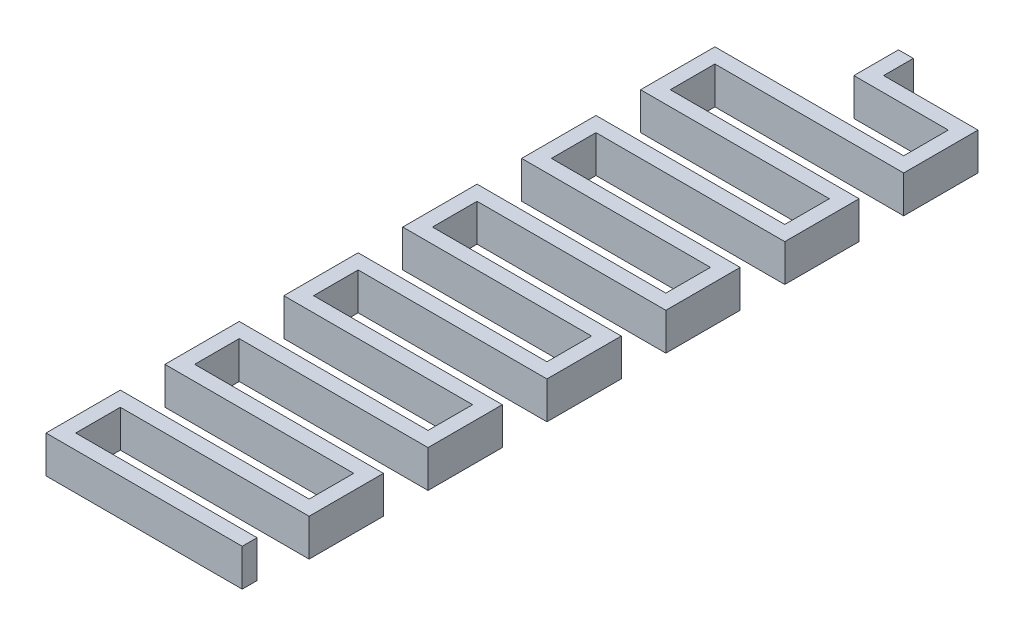
from build123d import *

# Parameters (mm, degrees)
EXTRUDE_THIN1_DEPTH = 5


with BuildPart() as part:
    # Sketch1 → Extrude-Thin1 (new body)
    with BuildSketch(Plane(origin=(0, 0, 0), x_dir=(1, 0, 0), z_dir=(0, 1, 0))):
        Polygon((-1, 0), (-1, -6), (11.7, -6), (11.7, -12), (-13.7, -12), (-13.7, -22), (11.7, -22), (11.7, -28), (-13.7, -28), (-13.7, -38), (11.7, -38), (11.7, -44), (-13.7, -44), (-13.7, -54), (11.7, -54), (11.7, -60), (-13.7, -60), (-13.7, -70), (11.7, -70), (11.7, -76), (-13.7, -76), (-13.7, -86), (11.7, -86), (11.7, -92), (-13.7, -92), (-13.7, -102), (12.7, -102), (12.7, -100), (-11.7, -100), (-11.7, -94), (13.7, -94), (13.7, -84), (-11.7, -84), (-11.7, -78), (13.7, -78), (13.7, -68), (-11.7, -68), (-11.7, -62), (13.7, -62), (13.7, -52), (-11.7, -52), (-11.7, -46), (13.7, -46), (13.7, -36), (-11.7, -36), (-11.7, -30), (13.7, -30), (13.7, -20), (-11.7, -20), (-11.7, -14), (13.7, -14), (13.7, -4), (1, -4), (1, 0), align=None)
    extrude(amount=EXTRUDE_THIN1_DEPTH)


solid = part.part
